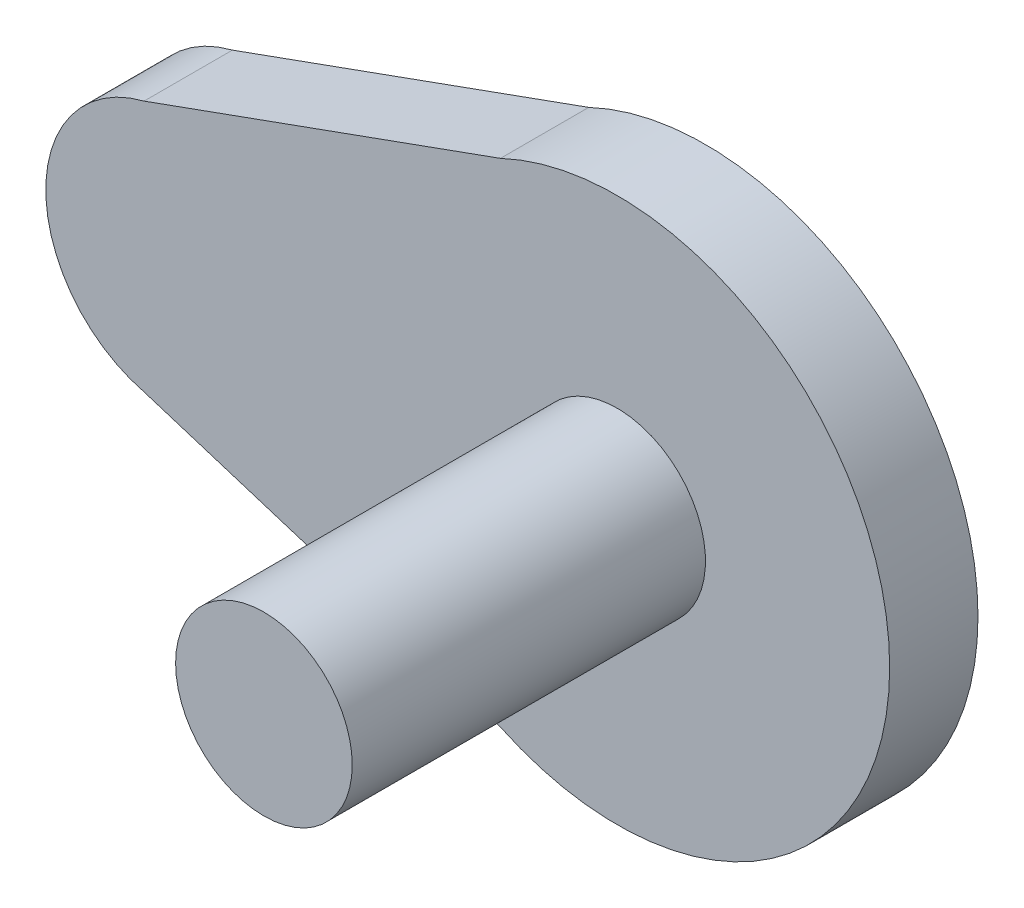
from build123d import *

# Parameters (mm, degrees)
BOSS_EXTRUDE1_DEPTH = 5
SKETCH2_R           = 5
BOSS_EXTRUDE2_DEPTH = 20
SKETCH3_R           = 2.5
BOSS_EXTRUDE3_DEPTH = 5


with BuildPart() as part:
    # Sketch1 → Boss-Extrude1 (new body)
    with BuildSketch(Plane.XY):
        with BuildLine():
            Line((0, 14.259541246), (20.176972809, 21.540123656))
            ThreePointArc((20.176972809, 21.540123656), (42.215740985, 7.597057881), (20.176972809, -6.346007893))
            Line((20.176972809, -6.346007893), (0, 0))
            ThreePointArc((0, 0), (-5.564259015, 7.129770623), (0, 14.259541246))
        make_face()
    extrude(amount=BOSS_EXTRUDE1_DEPTH)

    # Sketch2 → Boss-Extrude2 (add)
    with BuildSketch(Plane.XY.offset(5)):
        with Locations((26.785740985, 7.597057881)):
            Circle(SKETCH2_R)
    extrude(amount=BOSS_EXTRUDE2_DEPTH)

    # Sketch3 → Boss-Extrude3 (add)
    with BuildSketch(Plane(origin=(0, 0, 0), x_dir=(-1, 0, 0), z_dir=(0, 0, -1))):
        with Locations((-1.785740985, 7.129770623)):
            Circle(SKETCH3_R)
    extrude(amount=BOSS_EXTRUDE3_DEPTH)


solid = part.part
